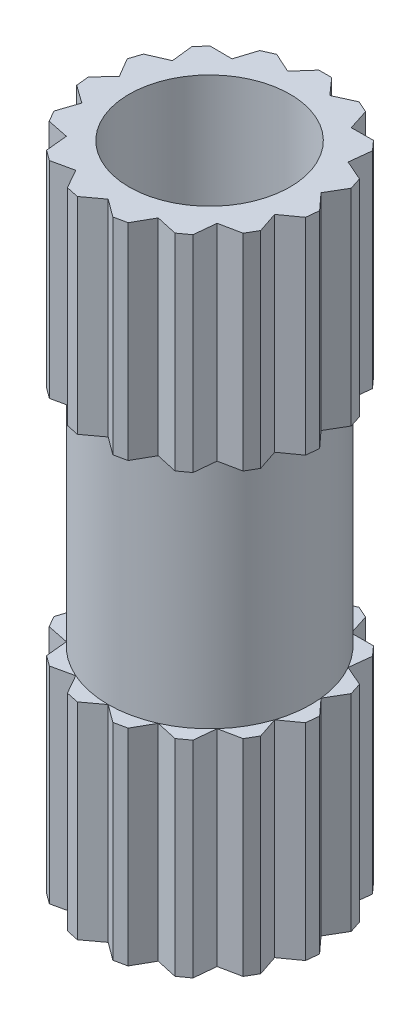
from build123d import *

# Parameters (mm, degrees)
SKETCH1_R           = 1.575
SKETCH1_R_2         = 1.25
BOSS_EXTRUDE1_DEPTH = 5
BOSS_EXTRUDE2_DEPTH = 3.2


with BuildPart() as part:
    # Sketch1 → Boss-Extrude1 (new body)
    with BuildSketch(Plane(origin=(0, 0, 0), x_dir=(1, 0, 0), z_dir=(0, 1, 0))):
        Circle(SKETCH1_R)
        Circle(SKETCH1_R_2, mode=Mode.SUBTRACT)
    boss_extrude1 = extrude(amount=BOSS_EXTRUDE1_DEPTH)

    # Sketch2 → Boss-Extrude2 (add)
    with BuildSketch(Plane(origin=(0, 5, 0), x_dir=(1, 0, 0), z_dir=(0, 1, 0))):
        with BuildLine():
            ThreePointArc((-0.925761772, 1.274201766), (-0.640610213, 1.438834096), (-0.327460913, 1.540582471))
            Line((-0.327460913, 1.540582471), (-0.639640715, 1.682515901))
            Line((-0.639640715, 1.682515901), (-0.822349806, 1.601168572))
            Line((-0.822349806, 1.601168572), (-0.925761772, 1.274201766))
        make_face()
        with BuildLine():
            Line((-0.1, 1.797220076), (-0.327460913, 1.540582471))
            ThreePointArc((-0.327460913, 1.540582471), (0, 1.575), (0.327460913, 1.540582471))
            Line((0.327460913, 1.540582471), (0.1, 1.797220076))
            Line((0.1, 1.797220076), (-0.1, 1.797220076))
        make_face()
        with BuildLine():
            Line((0.639640715, 1.682515901), (0.327460913, 1.540582471))
            ThreePointArc((0.327460913, 1.540582471), (0.640610213, 1.438834096), (0.925761772, 1.274201766))
            Line((0.925761772, 1.274201766), (0.822349806, 1.601168572))
            Line((0.822349806, 1.601168572), (0.639640715, 1.682515901))
        make_face()
        with BuildLine():
            ThreePointArc((-1.363990011, 0.7875), (-1.1704531, 1.053880705), (-0.925761772, 1.274201766))
            Line((-0.925761772, 1.274201766), (-1.268681739, 1.276889441))
            Line((-1.268681739, 1.276889441), (-1.40250786, 1.128260476))
            Line((-1.40250786, 1.128260476), (-1.363990011, 0.7875))
        make_face()
        with BuildLine():
            Line((1.268681739, 1.276889441), (0.925761772, 1.274201766))
            ThreePointArc((0.925761772, 1.274201766), (1.1704531, 1.053880705), (1.363990011, 0.7875))
            Line((1.363990011, 0.7875), (1.40250786, 1.128260476))
            Line((1.40250786, 1.128260476), (1.268681739, 1.276889441))
        make_face()
        with BuildLine():
            ThreePointArc((-1.566371985, 0.16463233), (-1.497914013, 0.486701766), (-1.363990011, 0.7875))
            Line((-1.363990011, 0.7875), (-1.678356165, 0.650477198))
            Line((-1.678356165, 0.650477198), (-1.740159564, 0.460265894))
            Line((-1.740159564, 0.460265894), (-1.566371985, 0.16463233))
        make_face()
        with BuildLine():
            Line((1.678356165, 0.650477198), (1.363990011, 0.7875))
            ThreePointArc((1.363990011, 0.7875), (1.497914013, 0.486701766), (1.566371985, 0.16463233))
            Line((1.566371985, 0.16463233), (1.740159564, 0.460265894))
            Line((1.740159564, 0.460265894), (1.678356165, 0.650477198))
        make_face()
        with BuildLine():
            ThreePointArc((-1.497914013, -0.486701766), (-1.566371985, -0.16463233), (-1.566371985, 0.16463233))
            Line((-1.566371985, 0.16463233), (-1.797827562, -0.088408463))
            Line((-1.797827562, -0.088408463), (-1.77692187, -0.287312842))
            Line((-1.77692187, -0.287312842), (-1.497914013, -0.486701766))
        make_face()
        with BuildLine():
            Line((1.797827562, -0.088408463), (1.566371985, 0.16463233))
            ThreePointArc((1.566371985, 0.16463233), (1.566371985, -0.16463233), (1.497914013, -0.486701766))
            Line((1.497914013, -0.486701766), (1.77692187, -0.287312842))
            Line((1.77692187, -0.287312842), (1.797827562, -0.088408463))
        make_face()
        with BuildLine():
            ThreePointArc((-1.1704531, -1.053880705), (-1.363990011, -0.7875), (-1.497914013, -0.486701766))
            Line((-1.497914013, -0.486701766), (-1.606438242, -0.812007497))
            Line((-1.606438242, -0.812007497), (-1.506438242, -0.985212578))
            Line((-1.506438242, -0.985212578), (-1.1704531, -1.053880705))
        make_face()
        with BuildLine():
            ThreePointArc((-0.640610213, -1.438834096), (-0.925761772, -1.274201766), (-1.1704531, -1.053880705))
            Line((-1.1704531, -1.053880705), (-1.137281155, -1.395203059))
            Line((-1.137281155, -1.395203059), (-0.975477756, -1.512760109))
            Line((-0.975477756, -1.512760109), (-0.640610213, -1.438834096))
        make_face()
        with BuildLine():
            Line((1.606438242, -0.812007497), (1.497914013, -0.486701766))
            ThreePointArc((1.497914013, -0.486701766), (1.363990011, -0.7875), (1.1704531, -1.053880705))
            Line((1.1704531, -1.053880705), (1.506438242, -0.985212578))
            Line((1.506438242, -0.985212578), (1.606438242, -0.812007497))
        make_face()
        with BuildLine():
            ThreePointArc((0, -1.575), (-0.327460913, -1.540582471), (-0.640610213, -1.438834096))
            Line((-0.640610213, -1.438834096), (-0.471477825, -1.737155336))
            Line((-0.471477825, -1.737155336), (-0.275848305, -1.778737674))
            Line((-0.275848305, -1.778737674), (0, -1.575))
        make_face()
        with BuildLine():
            Line((1.137281155, -1.395203059), (1.1704531, -1.053880705))
            ThreePointArc((1.1704531, -1.053880705), (0.925761772, -1.274201766), (0.640610213, -1.438834096))
            Line((0.640610213, -1.438834096), (0.975477756, -1.512760109))
            Line((0.975477756, -1.512760109), (1.137281155, -1.395203059))
        make_face()
        with BuildLine():
            ThreePointArc((0.640610213, -1.438834096), (0.327460913, -1.540582471), (0, -1.575))
            Line((0, -1.575), (0.275848305, -1.778737674))
            Line((0.275848305, -1.778737674), (0.471477825, -1.737155336))
            Line((0.471477825, -1.737155336), (0.640610213, -1.438834096))
        make_face()
    boss_extrude2 = extrude(amount=-BOSS_EXTRUDE2_DEPTH)

    # Mirror1: Boss-Extrude1, Boss-Extrude2 across plane
    add(boss_extrude1.mirror(Plane.ZX))
    add(boss_extrude2.mirror(Plane.ZX))


solid = part.part
